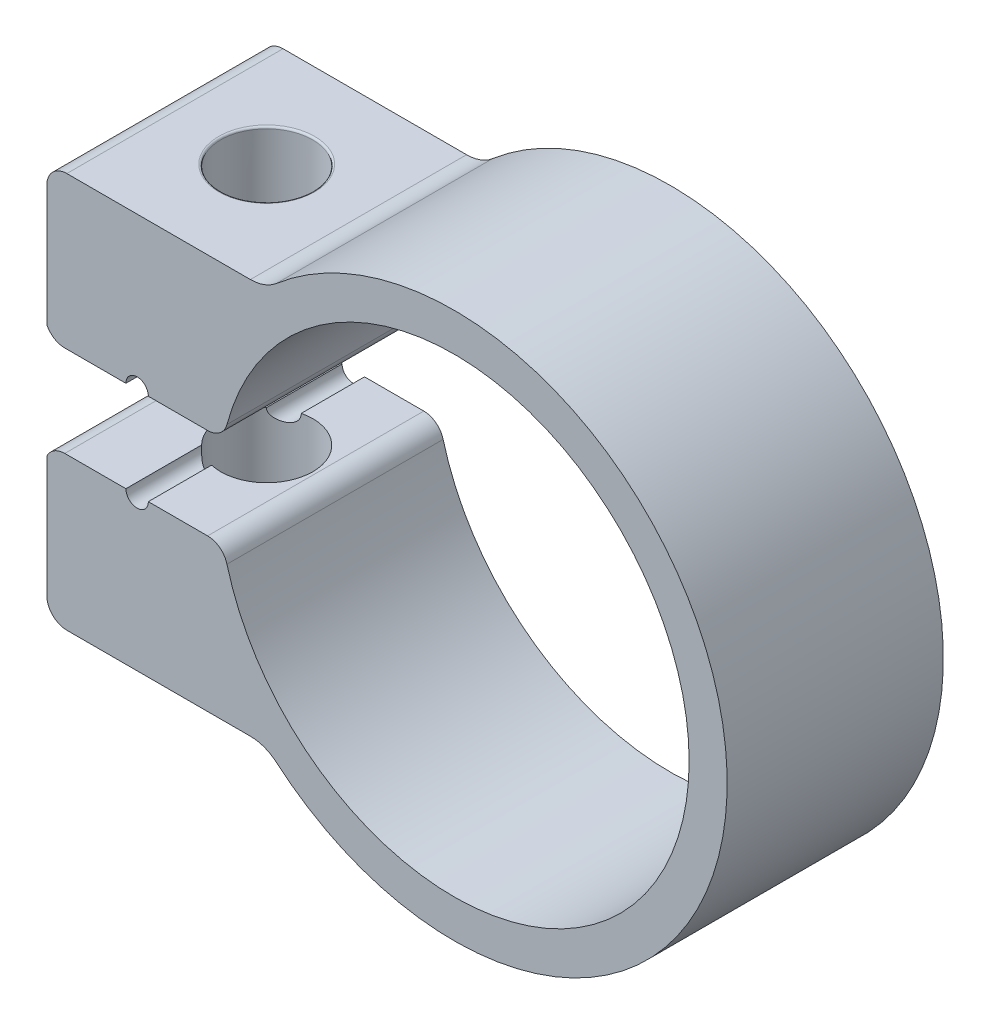
from build123d import *

# Parameters (mm, degrees)
BOSS_EXTRUDE1_DEPTH = 13.716
SKETCH2_R           = 5.4864
CUT_EXTRUDE1_DEPTH  = 3.6068
SKETCH3_R           = 2.921
CUT_EXTRUDE2_DEPTH  = 27.267149632
FILLET1_R           = 0.127
FILLET2_R           = 0.127
FILLET3_R           = 1.27
FILLET4_R           = 0.127


with BuildPart() as part:
    # Sketch1 → Boss-Extrude1 (new body)
    with BuildSketch(Plane.XY):
        with BuildLine():
            Line((-18.286658229, -2.8956), (-14.409782184, -2.8956))
            ThreePointArc((-14.409782184, -2.8956), (-13.697921632, -3.607460552), (-12.986061079, -2.8956))
            Line((-12.986061079, -2.8956), (-9.224054916, -2.8956))
            ThreePointArc((-9.224054916, -2.8956), (-8.450188338, -3.158609176), (-7.996847762, -3.838701544))
            ThreePointArc((-7.996847762, -3.838701544), (9.003275389, -14.686851959), (21.268740456, 1.3208))
            ThreePointArc((21.268740456, 1.3208), (7.692360315, 14.858458112), (-7.996847762, 3.838701544))
            ThreePointArc((-7.996847762, 3.838701544), (-8.450188338, 3.158609176), (-9.224054916, 2.8956))
            Line((-9.224054916, 2.8956), (-12.986061079, 2.8956))
            ThreePointArc((-12.986061079, 2.8956), (-13.697921632, 3.607460552), (-14.409782184, 2.8956))
            Line((-14.409782184, 2.8956), (-18.286658229, 2.8956))
            ThreePointArc((-18.286658229, 2.8956), (-18.958421102, 3.087808442), (-19.426847762, 3.606254106))
            Line((-19.426847762, 3.606254106), (-19.426847762, 11.2776))
            ThreePointArc((-19.426847762, 11.2776), (-19.054873374, 12.175625612), (-18.156847762, 12.5476))
            Line((-18.156847762, 12.5476), (-6.510253262, 12.5476))
            ThreePointArc((-6.510253262, 12.5476), (-5.629373118, 12.705237691), (-4.857831488, 13.158584116))
            ThreePointArc((-4.857831488, 13.158584116), (13.050680986, 16.004898652), (23.689927776, 1.3208))
            ThreePointArc((23.689927776, 1.3208), (14.251434441, -15.452408322), (-4.857831488, -13.158584116))
            ThreePointArc((-4.857831488, -13.158584116), (-5.629373118, -12.705237691), (-6.510253262, -12.5476))
            Line((-6.510253262, -12.5476), (-18.156847762, -12.5476))
            ThreePointArc((-18.156847762, -12.5476), (-19.054873374, -12.175625612), (-19.426847762, -11.2776))
            Line((-19.426847762, -11.2776), (-19.426847762, -3.606254106))
            ThreePointArc((-19.426847762, -3.606254106), (-18.958421102, -3.087808442), (-18.286658229, -2.8956))
        make_face()
    extrude(amount=BOSS_EXTRUDE1_DEPTH)

    # Sketch2 → Cut-Extrude1 (cut)
    with BuildSketch(Plane.XZ.offset(12.5476)):
        with Locations((-12.333550512, 6.858)):
            Circle(SKETCH2_R)
    extrude(amount=-CUT_EXTRUDE1_DEPTH, mode=Mode.SUBTRACT)

    # Sketch3 → Cut-Extrude2 (cut, through all)
    with BuildSketch(Plane.XZ.offset(8.9408)):
        with Locations((-12.333550512, 6.858)):
            Circle(SKETCH3_R)
    extrude(amount=-CUT_EXTRUDE2_DEPTH, mode=Mode.SUBTRACT)

    # Fillet1
    fillet1_edges = [part.edges().sort_by_distance(p)[0] for p in [
        (-15.254550512, 12.5476, 6.858),
    ]]
    fillet(fillet1_edges, radius=FILLET1_R)

    # Fillet2
    fillet2_edges = [part.edges().sort_by_distance(p)[0] for p in [
        (-17.819950512, -12.5476, 6.858),
    ]]
    fillet(fillet2_edges, radius=FILLET2_R)

    # Fillet3
    fillet3_edges = [part.edges().sort_by_distance(p)[0] for p in [
        (-17.819950512, -8.9408, 6.858),
    ]]
    fillet(fillet3_edges, radius=FILLET3_R)

    # Fillet4
    fillet4_edges = [part.edges().sort_by_distance(p)[0] for p in [
        (-15.254550512, -8.9408, 6.858),
    ]]
    fillet(fillet4_edges, radius=FILLET4_R)


solid = part.part
